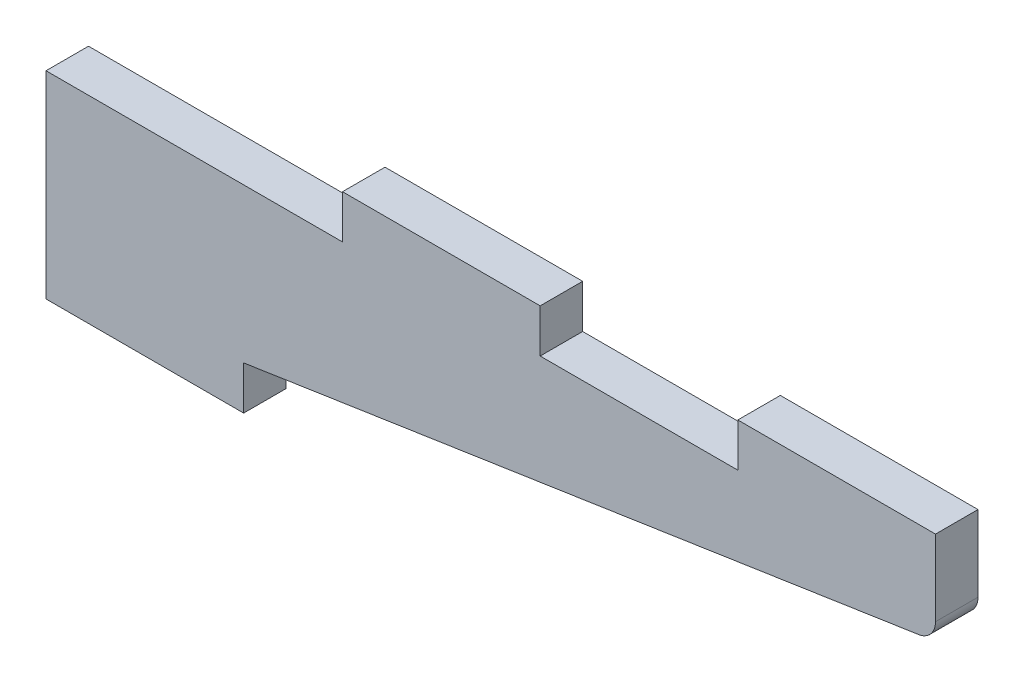
from build123d import *

# Parameters (mm, degrees)
BOSS_EXTRUDE1_DEPTH = 5.461
FILLET1_R           = 2.54


with BuildPart() as part:
    # Sketch1 → Boss-Extrude1 (new body)
    with BuildSketch(Plane.XY):
        Polygon((0, 0), (0, 25.4), (38.1, 25.4), (38.1, 30.988), (63.5, 30.988), (63.5, 25.4), (88.9, 25.4), (88.9, 30.988), (114.3, 30.988), (114.3, 25.4), (114.3, 19.05), (25.4, 5.588), (25.4, 0), align=None)
    extrude(amount=BOSS_EXTRUDE1_DEPTH)

    # Fillet1
    fillet1_edges = [part.edges().sort_by_distance(p)[0] for p in [
        (114.3, 19.05, 2.7305),
    ]]
    fillet(fillet1_edges, radius=FILLET1_R)


solid = part.part
